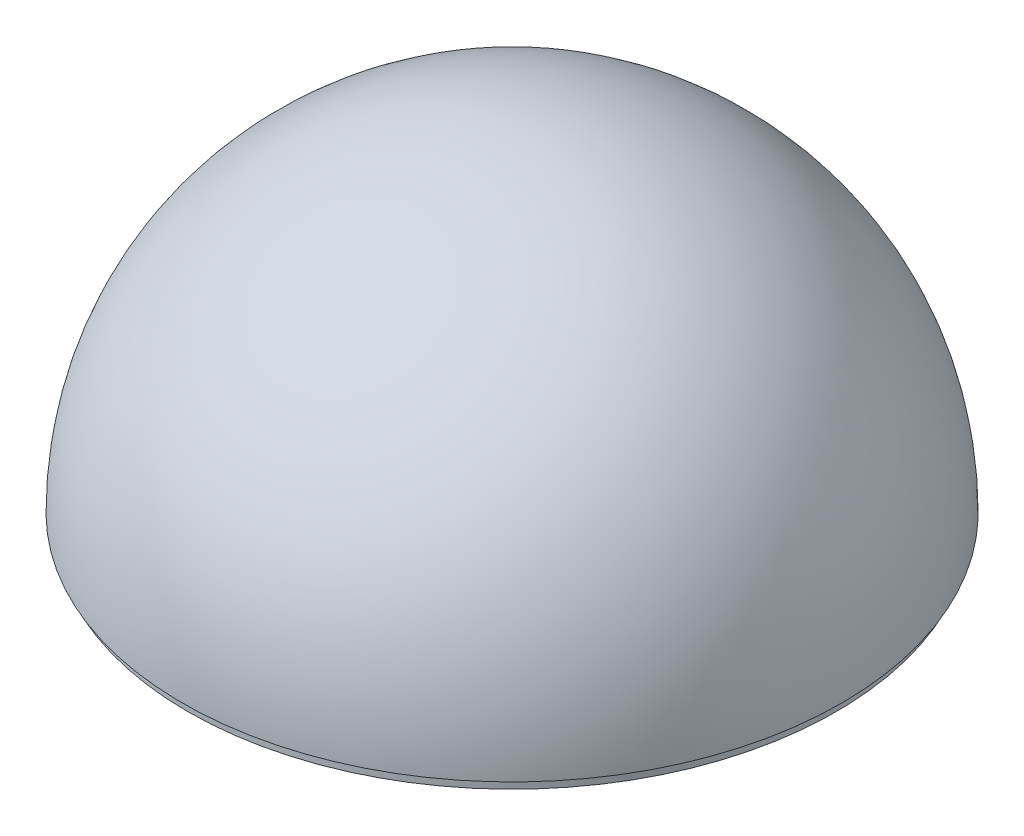
from build123d import *

# Parameters (mm, degrees)
REVOLVE1_ANGLE      = 180
SHELL1_T            = 2.54
SKETCH2_R           = 152.4
BOSS_EXTRUDE1_DEPTH = 4.7625


with BuildPart() as part:
    # Sketch1 → Revolve1 (revolve)
    with BuildSketch(Plane(origin=(0, 0, 0), x_dir=(1, 0, 0), z_dir=(0, 1, 0))):
        with BuildLine():
            Line((0, 152.4), (0, -152.4))
            ThreePointArc((0, -152.4), (152.4, 0), (0, 152.4))
        make_face()
    revolve(axis=Axis((0, 0, -152.4), (0, 0, 1)), revolution_arc=REVOLVE1_ANGLE)

    # Shell1
    shell1_openings = [part.faces().sort_by_distance(p)[0] for p in [
        (0, 0, 0),
    ]]
    offset(amount=SHELL1_T, openings=shell1_openings)


with BuildPart() as body_2:
    # Sketch2 → Boss-Extrude1 (new body)
    with BuildSketch(Plane(origin=(0, 0, 0), x_dir=(1, 0, 0), z_dir=(0, 1, 0))):
        with Locations(Location((0, 0, 0), (0, 0, 270))):
            Circle(SKETCH2_R)
    extrude(amount=-BOSS_EXTRUDE1_DEPTH)


solid = Compound([part.part, body_2.part])
